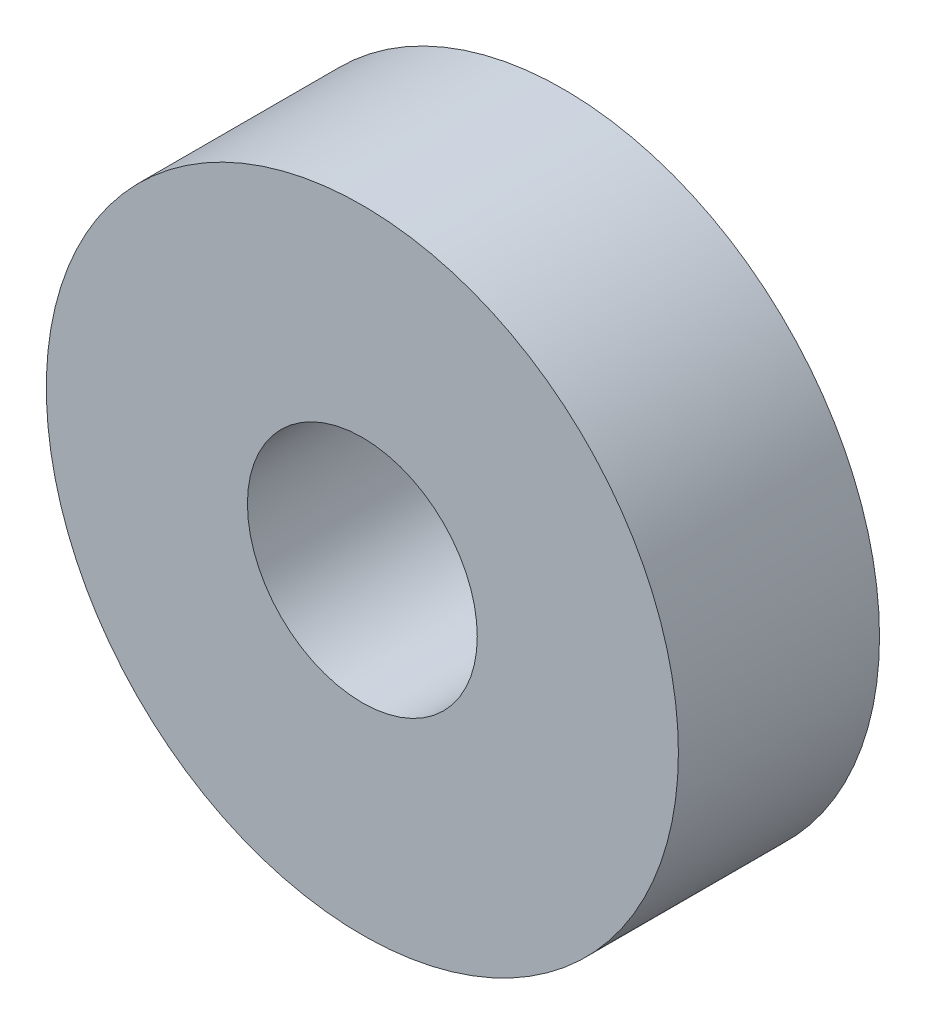
from build123d import *

# Parameters (mm, degrees)
SKETCH1_R           = 11
SKETCH1_R_2         = 4
BOSS_EXTRUDE1_DEPTH = 3.5


with BuildPart() as part:
    # Sketch1 → Boss-Extrude1 (new, symmetric)
    with BuildSketch(Plane.XY):
        Circle(SKETCH1_R)
        Circle(SKETCH1_R_2, mode=Mode.SUBTRACT)
    extrude(amount=BOSS_EXTRUDE1_DEPTH, both=True)


solid = part.part
